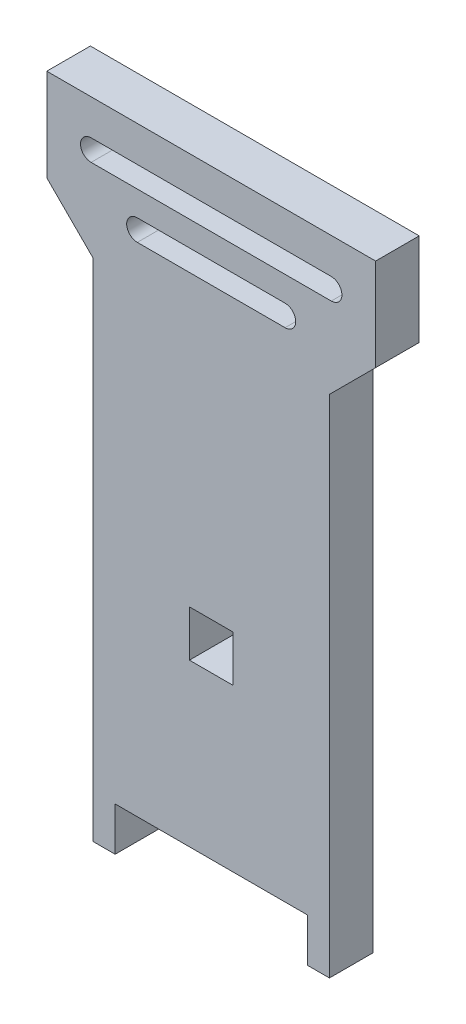
from build123d import *

# Parameters (mm, degrees)
SKETCH1_W           = 5.9944
SKETCH1_H           = 6.35
BOSS_EXTRUDE1_DEPTH = 5.9944


with BuildPart() as part:
    # Sketch1 → Boss-Extrude1 (new body)
    with BuildSketch(Plane.XY):
        Polygon((16.256, 0), (13.208, 0), (13.208, 5.9944), (-13.208, 5.9944), (-13.208, 0), (-16.256, 0), (-16.256, 69.4944), (-22.606, 75.8444), (-22.606, 88.5444), (22.606, 88.5444), (22.606, 75.8444), (16.256, 69.4944), align=None)
        with Locations((0, 31.3944)):
            Rectangle(SKETCH1_W, SKETCH1_H, mode=Mode.SUBTRACT)
        with BuildLine():
            Line((-10.16, 77.3049), (10.16, 77.3049))
            ThreePointArc((10.16, 77.3049), (11.6205, 75.8444), (10.16, 74.3839))
            Line((10.16, 74.3839), (-10.16, 74.3839))
            ThreePointArc((-10.16, 74.3839), (-11.6205, 75.8444), (-10.16, 77.3049))
        make_face(mode=Mode.SUBTRACT)
        with BuildLine():
            Line((-16.51, 83.6549), (16.51, 83.6549))
            ThreePointArc((16.51, 83.6549), (17.9705, 82.1944), (16.51, 80.7339))
            Line((16.51, 80.7339), (-16.51, 80.7339))
            ThreePointArc((-16.51, 80.7339), (-17.9705, 82.1944), (-16.51, 83.6549))
        make_face(mode=Mode.SUBTRACT)
    extrude(amount=BOSS_EXTRUDE1_DEPTH)


solid = part.part
